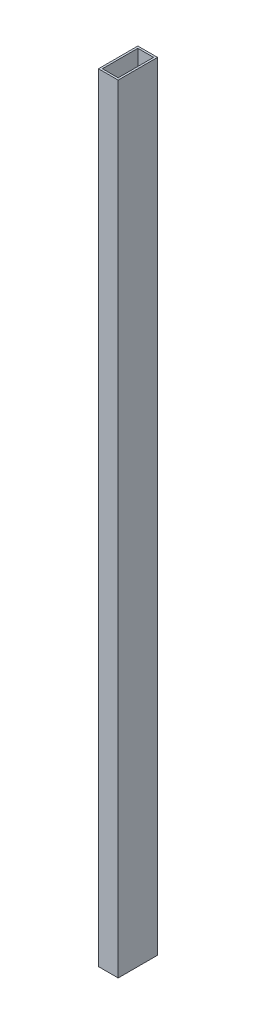
from build123d import *

# Parameters (mm, degrees)
SKETCH_1_W      = 20
SKETCH_1_H      = 40
SKETCH_1_W_2    = 16
SKETCH_1_H_2    = 36
EXTRUDE_1_DEPTH = 790


with BuildPart() as part:
    # Эскиз1 → Вытянуть-Тонкостенный1 (new body)
    with BuildSketch(Plane(origin=(0, 0, 0), x_dir=(1, 0, 0), z_dir=(0, 1, 0))):
        Rectangle(SKETCH_1_W, SKETCH_1_H)
        Rectangle(SKETCH_1_W_2, SKETCH_1_H_2, mode=Mode.SUBTRACT)
    extrude(amount=EXTRUDE_1_DEPTH)


solid = part.part
